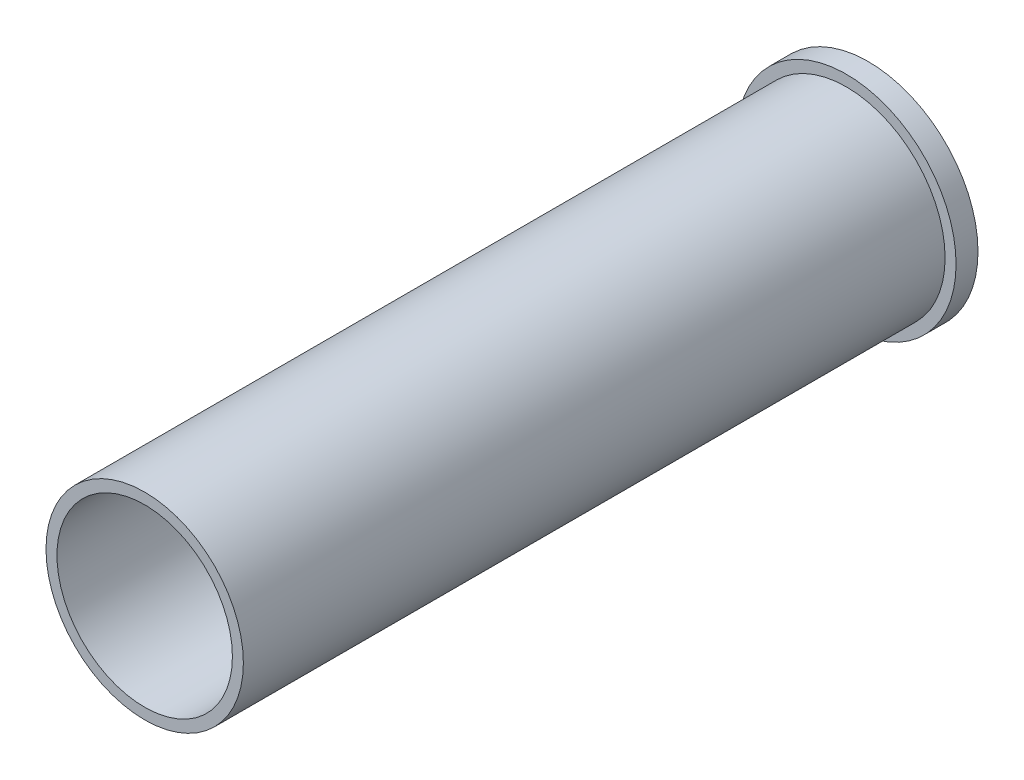
from build123d import *

# Parameters (mm, degrees)
SKETCH1_R           = 63.5
SKETCH1_R_2         = 50.8
BOSS_EXTRUDE1_DEPTH = 12.7
BOSS_EXTRUDE2_START = 406.4
SKETCH1_3_R         = 57.15
SKETCH1_3_R_2       = 50.8
BOSS_EXTRUDE2_DEPTH = 406.4


with BuildPart() as part:
    # Sketch1 → Boss-Extrude1 (new body)
    with BuildSketch(Plane.XY):
        Circle(SKETCH1_R)
        Circle(SKETCH1_R_2, mode=Mode.SUBTRACT)
    extrude(amount=-BOSS_EXTRUDE1_DEPTH)

    # Sketch1_3 → Boss-Extrude2 (add)
    with BuildSketch(Plane.XY.offset(BOSS_EXTRUDE2_START)):
        Circle(SKETCH1_3_R)
        Circle(SKETCH1_3_R_2, mode=Mode.SUBTRACT)
    extrude(amount=-BOSS_EXTRUDE2_DEPTH)


solid = part.part
